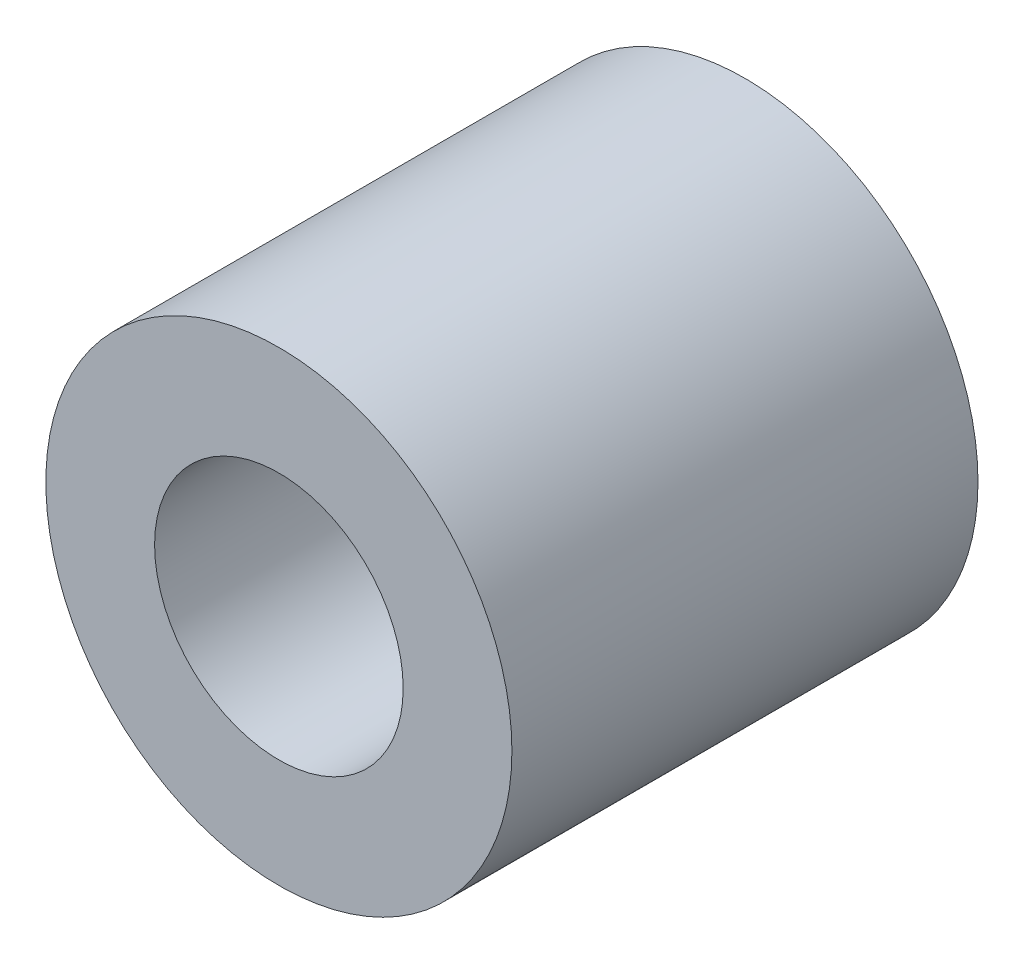
from build123d import *

# Parameters (mm, degrees)
SKETCH_7_W        = 3
SKETCH_7_H        = 1.4
HOLE_WIZARD_M21_D = 1.6
SKETCH_47_R       = 1.5
SKETCH_47_R_2     = 1.4
EXTRUDE_1_DEPTH   = 3


with BuildPart() as part:
    # Эскиз7 → Повернуть1 (revolve)
    with BuildSketch(Plane(origin=(0, 0, 0), x_dir=(0, 0, -1), z_dir=(1, 0, 0))):
        with Locations((1.5, 0.7)):
            Rectangle(SKETCH_7_W, SKETCH_7_H)
    revolve(axis=Axis((0, 0, 0), (0, 0, -1)))

    # Отверстие обработанное метчиком M21 (through all)
    with Locations(Plane.XY):
        with Locations((0, 0)):
            Hole(HOLE_WIZARD_M21_D / 2)

    # Эскиз47 → Бобышка-Вытянуть1 (add)
    with BuildSketch(Plane.XY):
        Circle(SKETCH_47_R)
        Circle(SKETCH_47_R_2, mode=Mode.SUBTRACT)
    extrude(amount=-EXTRUDE_1_DEPTH)


solid = part.part
